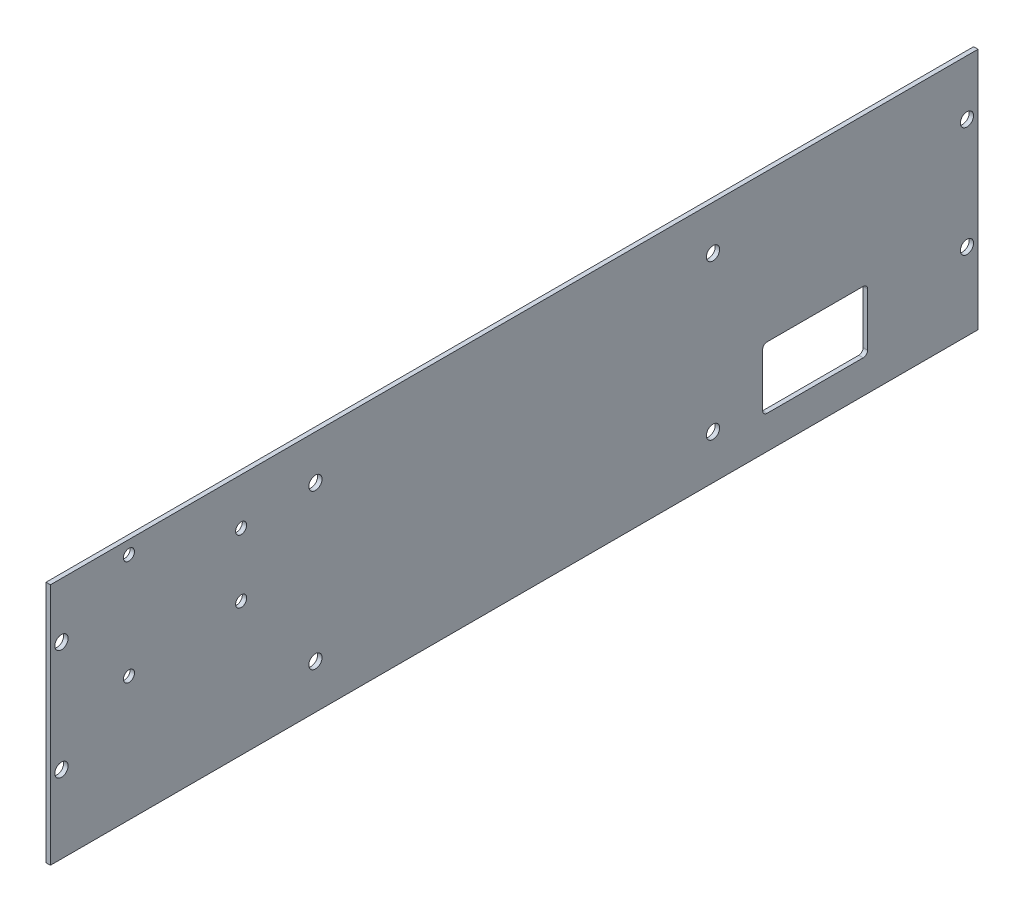
from build123d import *

# Parameters (mm, degrees)
SKETCH1_W           = 420
SKETCH1_H           = 110
BOSS_EXTRUDE1_DEPTH = 2
CUT_EXTRUDE1_REACH  = 4
SKETCH2_R           = 3
CUT_EXTRUDE2_REACH  = 4
SKETCH3_R           = 3
SKETCH3_R_2         = 2.5
SKETCH3_W           = 47.5
SKETCH3_H           = 28
FILLET1_R           = 2


with BuildPart() as part:
    # Sketch1 → Boss-Extrude1 (new body)
    with BuildSketch(Plane.ZY.offset(26.051745534)):
        with Locations((184.692172039, 45)):
            Rectangle(SKETCH1_W, SKETCH1_H)
    extrude(amount=BOSS_EXTRUDE1_DEPTH)

    # Sketch2 → Cut-Extrude1 (cut, up to next)
    with BuildSketch(Plane.ZY.offset(28.051745534), mode=Mode.PRIVATE) as cut_extrude1_sk1:
        with Locations((-20.307827961, 75)):
            Circle(SKETCH2_R)
    cut_extrude1_tool1 = extrude(cut_extrude1_sk1.sketch, amount=-CUT_EXTRUDE1_REACH, mode=Mode.PRIVATE) & part.part
    add(cut_extrude1_tool1.solids().sort_by_distance((-28.051746, 75, -20.307828))[0], mode=Mode.SUBTRACT)
    # Sketch2 → Cut-Extrude1 (cut, up to next)
    with BuildSketch(Plane.ZY.offset(28.051745534), mode=Mode.PRIVATE) as cut_extrude1_sk2:
        with Locations((-20.307827961, 25)):
            Circle(SKETCH2_R)
    cut_extrude1_tool2 = extrude(cut_extrude1_sk2.sketch, amount=-CUT_EXTRUDE1_REACH, mode=Mode.PRIVATE) & part.part
    add(cut_extrude1_tool2.solids().sort_by_distance((-28.051746, 25, -20.307828))[0], mode=Mode.SUBTRACT)
    # Sketch2 → Cut-Extrude1 (cut, up to next)
    with BuildSketch(Plane.ZY.offset(28.051745534), mode=Mode.PRIVATE) as cut_extrude1_sk3:
        with Locations((389.692172039, 75)):
            Circle(SKETCH2_R)
    cut_extrude1_tool3 = extrude(cut_extrude1_sk3.sketch, amount=-CUT_EXTRUDE1_REACH, mode=Mode.PRIVATE) & part.part
    add(cut_extrude1_tool3.solids().sort_by_distance((-28.051746, 75, 389.692172))[0], mode=Mode.SUBTRACT)
    # Sketch2 → Cut-Extrude1 (cut, up to next)
    with BuildSketch(Plane.ZY.offset(28.051745534), mode=Mode.PRIVATE) as cut_extrude1_sk4:
        with Locations((389.692172039, 25)):
            Circle(SKETCH2_R)
    cut_extrude1_tool4 = extrude(cut_extrude1_sk4.sketch, amount=-CUT_EXTRUDE1_REACH, mode=Mode.PRIVATE) & part.part
    add(cut_extrude1_tool4.solids().sort_by_distance((-28.051746, 25, 389.692172))[0], mode=Mode.SUBTRACT)

    # Sketch3 → Cut-Extrude2 (cut, up to next)
    with BuildSketch(Plane.ZY.offset(28.051745534), mode=Mode.PRIVATE) as cut_extrude2_sk1:
        with Locations((94.692172039, 10)):
            Circle(SKETCH3_R)
    cut_extrude2_tool1 = extrude(cut_extrude2_sk1.sketch, amount=-CUT_EXTRUDE2_REACH, mode=Mode.PRIVATE) & part.part
    add(cut_extrude2_tool1.solids().sort_by_distance((-28.051746, 10, 94.692172))[0], mode=Mode.SUBTRACT)
    # Sketch3 → Cut-Extrude2 (cut, up to next)
    with BuildSketch(Plane.ZY.offset(28.051745534), mode=Mode.PRIVATE) as cut_extrude2_sk2:
        with Locations((274.692172039, 10)):
            Circle(SKETCH3_R)
    cut_extrude2_tool2 = extrude(cut_extrude2_sk2.sketch, amount=-CUT_EXTRUDE2_REACH, mode=Mode.PRIVATE) & part.part
    add(cut_extrude2_tool2.solids().sort_by_distance((-28.051746, 10, 274.692172))[0], mode=Mode.SUBTRACT)
    # Sketch3 → Cut-Extrude2 (cut, up to next)
    with BuildSketch(Plane.ZY.offset(28.051745534), mode=Mode.PRIVATE) as cut_extrude2_sk3:
        with Locations((94.692172039, 80)):
            Circle(SKETCH3_R)
    cut_extrude2_tool3 = extrude(cut_extrude2_sk3.sketch, amount=-CUT_EXTRUDE2_REACH, mode=Mode.PRIVATE) & part.part
    add(cut_extrude2_tool3.solids().sort_by_distance((-28.051746, 80, 94.692172))[0], mode=Mode.SUBTRACT)
    # Sketch3 → Cut-Extrude2 (cut, up to next)
    with BuildSketch(Plane.ZY.offset(28.051745534), mode=Mode.PRIVATE) as cut_extrude2_sk4:
        with Locations((274.692172039, 80)):
            Circle(SKETCH3_R)
    cut_extrude2_tool4 = extrude(cut_extrude2_sk4.sketch, amount=-CUT_EXTRUDE2_REACH, mode=Mode.PRIVATE) & part.part
    add(cut_extrude2_tool4.solids().sort_by_distance((-28.051746, 80, 274.692172))[0], mode=Mode.SUBTRACT)
    # Sketch3 → Cut-Extrude2 (cut, up to next)
    with BuildSketch(Plane.ZY.offset(28.051745534), mode=Mode.PRIVATE) as cut_extrude2_sk5:
        with Locations((359.1226293, 94)):
            Circle(SKETCH3_R_2)
    cut_extrude2_tool5 = extrude(cut_extrude2_sk5.sketch, amount=-CUT_EXTRUDE2_REACH, mode=Mode.PRIVATE) & part.part
    add(cut_extrude2_tool5.solids().sort_by_distance((-28.051746, 94, 359.122629))[0], mode=Mode.SUBTRACT)
    # Sketch3 → Cut-Extrude2 (cut, up to next)
    with BuildSketch(Plane.ZY.offset(28.051745534), mode=Mode.PRIVATE) as cut_extrude2_sk6:
        with Locations((308.3226293, 79)):
            Circle(SKETCH3_R_2)
    cut_extrude2_tool6 = extrude(cut_extrude2_sk6.sketch, amount=-CUT_EXTRUDE2_REACH, mode=Mode.PRIVATE) & part.part
    add(cut_extrude2_tool6.solids().sort_by_distance((-28.051746, 79, 308.322629))[0], mode=Mode.SUBTRACT)
    # Sketch3 → Cut-Extrude2 (cut, up to next)
    with BuildSketch(Plane.ZY.offset(28.051745534), mode=Mode.PRIVATE) as cut_extrude2_sk7:
        with Locations((308.3226293, 50.4)):
            Circle(SKETCH3_R_2)
    cut_extrude2_tool7 = extrude(cut_extrude2_sk7.sketch, amount=-CUT_EXTRUDE2_REACH, mode=Mode.PRIVATE) & part.part
    add(cut_extrude2_tool7.solids().sort_by_distance((-28.051746, 50.4, 308.322629))[0], mode=Mode.SUBTRACT)
    # Sketch3 → Cut-Extrude2 (cut, up to next)
    with BuildSketch(Plane.ZY.offset(28.051745534), mode=Mode.PRIVATE) as cut_extrude2_sk8:
        with Locations((359.1226293, 46.4)):
            Circle(SKETCH3_R_2)
    cut_extrude2_tool8 = extrude(cut_extrude2_sk8.sketch, amount=-CUT_EXTRUDE2_REACH, mode=Mode.PRIVATE) & part.part
    add(cut_extrude2_tool8.solids().sort_by_distance((-28.051746, 46.4, 359.122629))[0], mode=Mode.SUBTRACT)
    # Sketch3 → Cut-Extrude2 (cut, up to next)
    with BuildSketch(Plane.ZY.offset(28.051745534), mode=Mode.PRIVATE) as cut_extrude2_sk9:
        with Locations((48.442172039, 19)):
            Rectangle(SKETCH3_W, SKETCH3_H)
    cut_extrude2_tool9 = extrude(cut_extrude2_sk9.sketch, amount=-CUT_EXTRUDE2_REACH, mode=Mode.PRIVATE) & part.part
    add(cut_extrude2_tool9.solids().sort_by_distance((-28.051746, 19, 48.442172))[0], mode=Mode.SUBTRACT)

    # Fillet1
    fillet1_edges = [part.edges().sort_by_distance(p)[0] for p in [
        (-27.051745534, 5, 24.692172039),
        (-27.051745534, 33, 24.692172039),
        (-27.051745534, 33, 72.192172039),
        (-27.051745534, 5, 72.192172039),
    ]]
    fillet(fillet1_edges, radius=FILLET1_R)


solid = part.part
